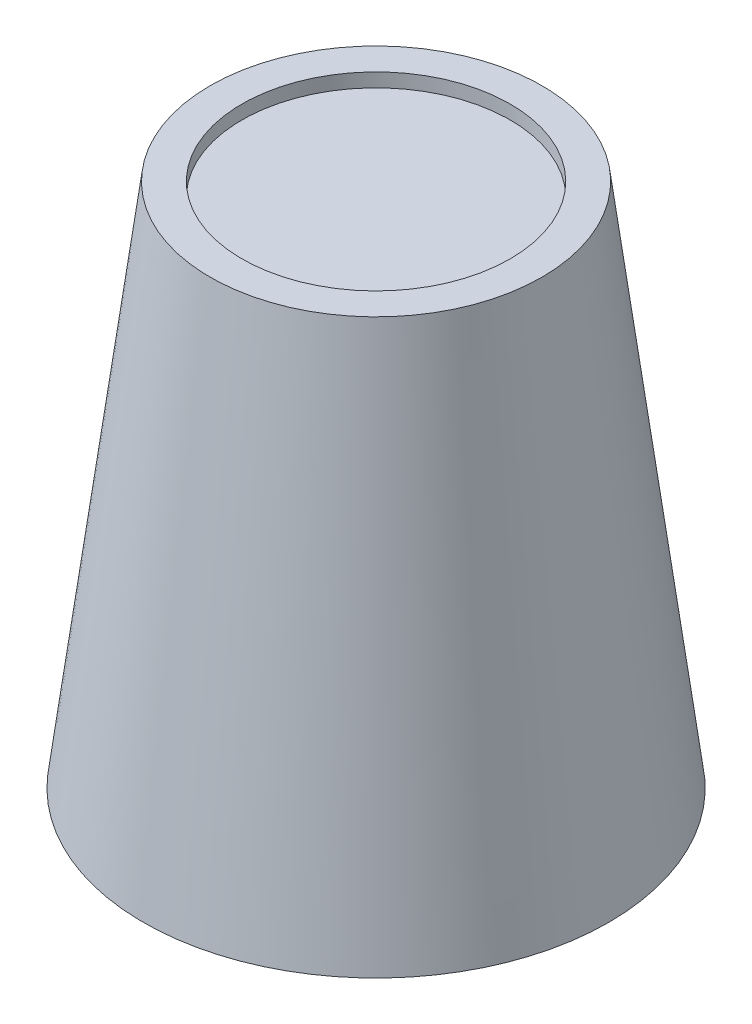
from build123d import *


with BuildPart() as part:
    # Эскиз2 → Повернуть1 (revolve)
    with BuildSketch(Plane.XY):
        Polygon((0, 9.846355146), (0, 9.346355146), (1.5, 9.346355146), (1.5, -3.153644854), (2.5, -3.153644854), (2.5, -5.153644854), (6, -5.153644854), (6, -8.653644854), (8.417004049, -8.653644854), (6, 10.346355146), (4.851809127, 10.346355146), (4.851809127, 9.846355146), align=None)
    revolve(axis=Axis((0, -1000, 0), (0, 1, 0)))


solid = part.part
